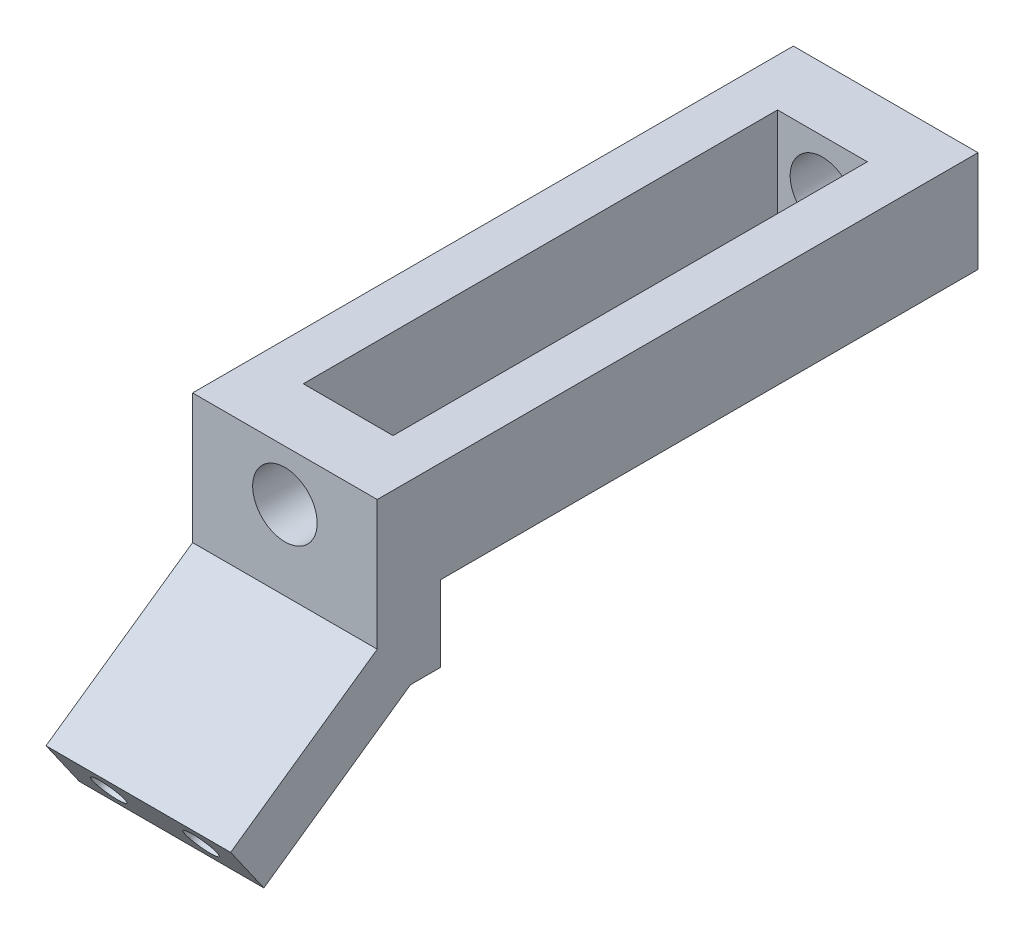
from build123d import *

# Parameters (mm, degrees)
SKETCH1_R           = 5.1
BOSS_EXTRUDE1_DEPTH = 10
SKETCH2_W           = 7.5
SKETCH2_H           = 16
BOSS_EXTRUDE2_DEPTH = 85
SKETCH3_W           = 29.2
SKETCH3_H           = 16
SKETCH3_R           = 5.1
BOSS_EXTRUDE3_DEPTH = 10
SKETCH4_W           = 29.2
SKETCH4_H           = 12
BOSS_EXTRUDE4_DEPTH = 10
CUT_EXTRUDE1_REACH  = 31.2
SKETCH6_W           = 29.2
SKETCH6_H           = 9.155809416
BOSS_EXTRUDE5_DEPTH = 28.3
SKETCH7_R           = 2.5
CUT_EXTRUDE2_DEPTH  = 20


with BuildPart() as part:
    # Sketch1 → Boss-Extrude1 (new body)
    with BuildSketch(Plane.XY):
        Polygon((-7.1, 8), (-14.6, 8), (-14.6, -8), (-7.1, -8), (7.1, -8), (14.6, -8), (14.6, 8), (7.1, 8), align=None)
        Circle(SKETCH1_R, mode=Mode.SUBTRACT)
    extrude(amount=BOSS_EXTRUDE1_DEPTH)

    # Sketch2 → Boss-Extrude2 (add)
    with BuildSketch(Plane.XY.offset(10)):
        with Locations((-10.85, 0)):
            Rectangle(SKETCH2_W, SKETCH2_H)
        with Locations((10.85, 0)):
            Rectangle(SKETCH2_W, SKETCH2_H)
    extrude(amount=BOSS_EXTRUDE2_DEPTH)

    # Sketch3 → Boss-Extrude3 (add)
    with BuildSketch(Plane.XY.offset(95)):
        Rectangle(SKETCH3_W, SKETCH3_H)
        Circle(SKETCH3_R, mode=Mode.SUBTRACT)
    extrude(amount=-BOSS_EXTRUDE3_DEPTH)

    # Sketch4 → Boss-Extrude4 (add)
    with BuildSketch(Plane.XY.offset(95)):
        with Locations((0, -14)):
            Rectangle(SKETCH4_W, SKETCH4_H)
    extrude(amount=-BOSS_EXTRUDE4_DEPTH)

    # Sketch5 → Cut-Extrude1 (cut, up to next)
    with BuildSketch(Plane(origin=(14.6, 0, 0), x_dir=(0, 0, -1), z_dir=(1, 0, 0)), mode=Mode.PRIVATE) as cut_extrude1_sk1:
        Polygon((-95, -12.5), (-89.748443463, -20), (-95, -20), align=None)
    cut_extrude1_tool1 = extrude(cut_extrude1_sk1.sketch, amount=-CUT_EXTRUDE1_REACH, mode=Mode.PRIVATE) & part.part
    add(cut_extrude1_tool1.solids().sort_by_distance((14.6, -17.5, 93.249481))[0], mode=Mode.SUBTRACT)

    # Sketch6 → Boss-Extrude5 (add)
    with BuildSketch(Plane(origin=(0, -48.747773592, 69.619035688), x_dir=(1, 0, 0), z_dir=(0, -0.573576436, 0.819152044))):
        with Locations((0, 39.672456192)):
            Rectangle(SKETCH6_W, SKETCH6_H)
    extrude(amount=BOSS_EXTRUDE5_DEPTH)

    # Sketch7 → Cut-Extrude2 (cut)
    with BuildSketch(Plane(origin=(0, -64.97998674, 92.801038541), x_dir=(1, 0, 0), z_dir=(0, -0.573576436, 0.819152044))):
        with Locations((-7.3, 39.672456192)):
            Circle(SKETCH7_R)
        with Locations((7.3, 39.672456192)):
            Circle(SKETCH7_R)
    extrude(amount=-CUT_EXTRUDE2_DEPTH, mode=Mode.SUBTRACT)


solid = part.part
